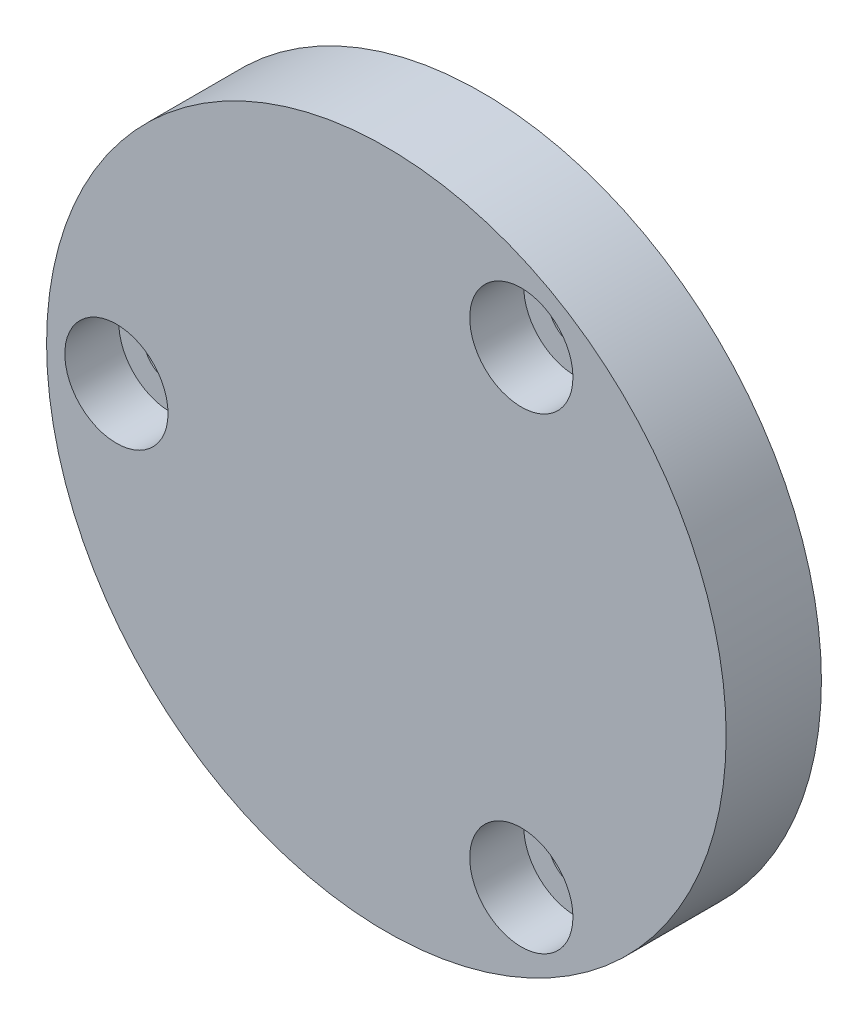
from build123d import *

# Parameters (mm, degrees)
ESQUISSE1_R                                        = 21.4
BOSS_EXTRU_1_DEPTH                                 = 6
ESQUISSE2_R                                        = 12.5
ENL_V_MAT_EXTRU_1_DEPTH                            = 3
CHAMBRAGE_POUR_VIS_T_TE_HEXAGONALE_M31_D           = 3.4
CHAMBRAGE_POUR_VIS_T_TE_HEXAGONALE_M31_DEPTH       = 8
CHAMBRAGE_POUR_VIS_T_TE_HEXAGONALE_M31_CBORE_D     = 6.5
CHAMBRAGE_POUR_VIS_T_TE_HEXAGONALE_M31_CBORE_DEPTH = 3.4
CHAMBRAGE_POUR_VIS_T_TE_HEXAGONALE_M31_TIP         = 1.021463052


with BuildPart() as part:
    # Esquisse1 → Boss.-Extru.1 (new body)
    with BuildSketch(Plane.XY):
        Circle(ESQUISSE1_R)
    extrude(amount=BOSS_EXTRU_1_DEPTH)

    # Esquisse2 → Enlèv. mat.-Extru.1 (cut)
    with BuildSketch(Plane(origin=(0, 0, 0), x_dir=(-1, 0, 0), z_dir=(0, 0, -1))):
        Circle(ESQUISSE2_R)
    extrude(amount=-ENL_V_MAT_EXTRU_1_DEPTH, mode=Mode.SUBTRACT)

    # Chambrage pour vis à tête hexagonale M31
    with Locations(Plane.XY.offset(6)):
        with Locations((-17, 0), (8.5, 14.722431864), (8.5, -14.722431864)):
            CounterBoreHole(CHAMBRAGE_POUR_VIS_T_TE_HEXAGONALE_M31_D / 2, CHAMBRAGE_POUR_VIS_T_TE_HEXAGONALE_M31_CBORE_D / 2, CHAMBRAGE_POUR_VIS_T_TE_HEXAGONALE_M31_CBORE_DEPTH, depth=CHAMBRAGE_POUR_VIS_T_TE_HEXAGONALE_M31_DEPTH)
            with Locations((0, 0, -(CHAMBRAGE_POUR_VIS_T_TE_HEXAGONALE_M31_DEPTH + CHAMBRAGE_POUR_VIS_T_TE_HEXAGONALE_M31_TIP / 2))):  # 118° drill point
                Cone(0, CHAMBRAGE_POUR_VIS_T_TE_HEXAGONALE_M31_D / 2, CHAMBRAGE_POUR_VIS_T_TE_HEXAGONALE_M31_TIP, mode=Mode.SUBTRACT)


solid = part.part
